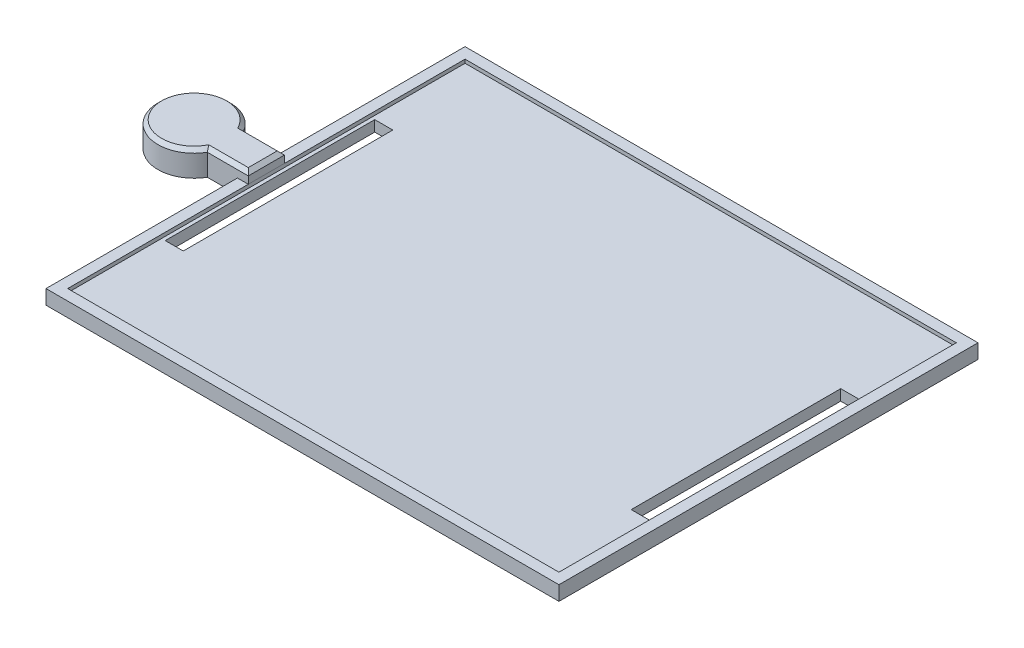
from build123d import *

# Parameters (mm, degrees)
SKETCH2_W                 = 142
SKETCH2_H                 = 116
BOSS_EXTRUDE2_DEPTH       = 4
SHELL1_T                  = -3
SKETCH4_W                 = 10
SKETCH4_H                 = 30
BOSS_EXTRUDE4_DEPTH       = 30
CUT_EXTRUDE1_DEPTH        = 31
CUT_EXTRUDE1_DEPTH_BACK   = 113
SKETCH6_W                 = 3
SKETCH6_H                 = 3.5
CUT_EXTRUDE2_DEPTH        = 31
CUT_EXTRUDE2_DEPTH_BACK   = 113
FILLET2_R                 = 2
SKETCH9_W                 = 22.5
SKETCH9_H                 = 12.1
CUT_EXTRUDE3_DEPTH        = 31
CUT_EXTRUDE3_DEPTH_BACK   = 10
SKETCH11_R                = 5.5
SKETCH11_R_2              = 4.25
BOSS_EXTRUDE6_DEPTH       = 17.5
M3X0_5_TAPPED_HOLE1_D     = 2.2
M3X0_5_TAPPED_HOLE1_DEPTH = 10
M3X0_5_TAPPED_HOLE1_TIP   = 0.660946681
SKETCH19_W                = 3
SKETCH19_H                = 10
BOSS_EXTRUDE7_DEPTH       = 3
BOSS_EXTRUDE7_DEPTH_BACK  = 4
CHAMFER1_SIZE             = 1
SKETCH27_W                = 14
SKETCH27_H                = 35
BOSS_EXTRUDE10_DEPTH      = 45
CUT_EXTRUDE4_DEPTH        = 45
SKETCH29_W                = 22.75
SKETCH29_H                = 12.15
CUT_EXTRUDE5_DEPTH        = 14
SKETCH37_R                = 4.25
CUT_EXTRUDE6_DEPTH        = 57.95
SKETCH38_W                = 5
SKETCH38_H                = 58
CUT_EXTRUDE7_DEPTH        = 8


with BuildPart() as part:
    # Sketch2 → Boss-Extrude2 (new body)
    with BuildSketch(Plane(origin=(0, 0, 0), x_dir=(1, 0, 0), z_dir=(0, 1, 0))):
        Rectangle(SKETCH2_W, SKETCH2_H)
    extrude(amount=BOSS_EXTRUDE2_DEPTH)

    # Shell1
    shell1_openings = [part.faces().sort_by_distance(p)[0] for p in [
        (0, 4, 0),
    ]]
    offset(amount=SHELL1_T, openings=shell1_openings, kind=Kind.INTERSECTION)

    # Sketch4 → Boss-Extrude4 (add)
    with BuildSketch(Plane.XZ):
        with Locations((-36, 0)):
            Rectangle(SKETCH4_W, SKETCH4_H)
        with Locations((19.05, 0)):
            Rectangle(SKETCH4_W, SKETCH4_H)
        with Locations((-10.95, 0)):
            Rectangle(SKETCH4_W, SKETCH4_H)
    extrude(amount=BOSS_EXTRUDE4_DEPTH)

    # Sketch5 → Cut-Extrude1 (cut, two sides)
    with BuildSketch(Plane.ZY.offset(41)) as cut_extrude1_sk:
        with BuildLine():
            ThreePointArc((-1.6e-08, -30), (-10.606601724, -25.606601712), (-15, -15))
            Line((-15, -15), (-15, -30))
            Line((-15, -30), (-1.6e-08, -30))
        make_face()
        with BuildLine():
            ThreePointArc((15, -15), (10.606601712, -25.606601724), (-1.6e-08, -30))
            Line((-1.6e-08, -30), (15, -30))
            Line((15, -30), (15, -15))
        make_face()
    extrude(amount=CUT_EXTRUDE1_DEPTH, mode=Mode.SUBTRACT)
    extrude(cut_extrude1_sk.sketch, amount=-CUT_EXTRUDE1_DEPTH_BACK, mode=Mode.SUBTRACT)

    # Sketch6 → Cut-Extrude2 (cut, two sides)
    with BuildSketch(Plane.ZY.offset(41)) as cut_extrude2_sk:
        with Locations((1.5, -1.75)):
            Rectangle(SKETCH6_W, SKETCH6_H)
    extrude(amount=CUT_EXTRUDE2_DEPTH, mode=Mode.SUBTRACT)
    extrude(cut_extrude2_sk.sketch, amount=-CUT_EXTRUDE2_DEPTH_BACK, mode=Mode.SUBTRACT)

    # Fillet2
    fillet2_edges = [part.edges().sort_by_distance(p)[0] for p in [
        (-31, 0, 9),
        (-41, 0, -7.5),
        (24.05, 0, 9),
        (14.05, 0, -7.5),
        (-5.95, 0, 9),
        (-15.95, 0, -7.5),
        (-31, 0, -7.5),
        (-41, 0, 9),
        (24.05, 0, -7.5),
        (14.05, 0, 9),
        (-5.95, 0, -7.5),
        (-15.95, 0, 9),
    ]]
    fillet(fillet2_edges, radius=FILLET2_R)

    # Sketch9 → Cut-Extrude3 (cut, two sides)
    with BuildSketch(Plane.ZY.offset(41)) as cut_extrude3_sk:
        with Locations((0, -15)):
            Rectangle(SKETCH9_W, SKETCH9_H)
    extrude(amount=CUT_EXTRUDE3_DEPTH, mode=Mode.SUBTRACT)
    extrude(cut_extrude3_sk.sketch, amount=-CUT_EXTRUDE3_DEPTH_BACK, mode=Mode.SUBTRACT)

    # Sketch11 → Boss-Extrude6 (add)
    with BuildSketch(Plane(origin=(-5.95, 0, 0), x_dir=(0, 0, -1), z_dir=(1, 0, 0))):
        with Locations((0, -20)):
            Circle(SKETCH11_R)
        with Locations((0, -20)):
            Circle(SKETCH11_R_2, mode=Mode.SUBTRACT)
    extrude(amount=BOSS_EXTRUDE6_DEPTH)

    # M3x0.5 Tapped Hole1
    with Locations(Plane.ZY.offset(41)):
        with Locations((13.85, -15)):
            Hole(M3X0_5_TAPPED_HOLE1_D / 2, depth=M3X0_5_TAPPED_HOLE1_DEPTH)
            with Locations((0, 0, -(M3X0_5_TAPPED_HOLE1_DEPTH + M3X0_5_TAPPED_HOLE1_TIP / 2))):  # 118° drill point
                Cone(0, M3X0_5_TAPPED_HOLE1_D / 2, M3X0_5_TAPPED_HOLE1_TIP, mode=Mode.SUBTRACT)

    # Sketch27 → Boss-Extrude10 (add)
    with BuildSketch(Plane.XZ):
        with Locations((-36, 2.5)):
            Rectangle(SKETCH27_W, SKETCH27_H)
    extrude(amount=BOSS_EXTRUDE10_DEPTH)

    # Sketch28 → Cut-Extrude4 (cut)
    with BuildSketch(Plane.ZY.offset(43)):
        with BuildLine():
            Line((15, 0), (15, -30))
            ThreePointArc((15, -30), (10.606601718, -40.606601718), (0, -45))
            Line((0, -45), (20, -45))
            Line((20, -45), (20, 0))
            Line((20, 0), (15, 0))
        make_face()
        with BuildLine():
            Line((-15, -45), (0, -45))
            ThreePointArc((0, -45), (-10.606601718, -40.606601718), (-15, -30))
            Line((-15, -30), (-15, -45))
        make_face()
    extrude(amount=-CUT_EXTRUDE4_DEPTH, mode=Mode.SUBTRACT)

    # Sketch29 → Cut-Extrude5 (cut)
    with BuildSketch(Plane.ZY.offset(43)):
        with Locations((0, -25)):
            Rectangle(SKETCH29_W, SKETCH29_H)
    extrude(amount=-CUT_EXTRUDE5_DEPTH, mode=Mode.SUBTRACT)

    # Sketch36 → M2 Clearance Hole1 (revolve, cut)
    with BuildSketch(Plane(origin=(-43, -25, 13.875), x_dir=(0, 0, 1), z_dir=(0, 1, 0))):
        Polygon((0, 0), (0, 14.721032743), (1.2, 14), (1.2, 0), align=None)
    revolve(axis=Axis((-49.35, -25, 13.875), (1, 0, 0)), mode=Mode.SUBTRACT)

    # Sketch37 → Cut-Extrude6 (cut, through all)
    with BuildSketch(Plane.ZY.offset(-14.05)):
        with Locations((0, -20)):
            Circle(SKETCH37_R)
    extrude(amount=-CUT_EXTRUDE6_DEPTH, mode=Mode.SUBTRACT)

    # Sketch38 → Cut-Extrude7 (cut, through all)
    with BuildSketch(Plane.XZ):
        with Locations((-64.5, 0)):
            Rectangle(SKETCH38_W, SKETCH38_H)
        with Locations((64.5, 0)):
            Rectangle(SKETCH38_W, SKETCH38_H)
    extrude(amount=-CUT_EXTRUDE7_DEPTH, mode=Mode.SUBTRACT)


with BuildPart() as body_2:
    # Sketch19 → Boss-Extrude7 (new body, two sides)
    with BuildSketch(Plane(origin=(0, 4, 0), x_dir=(1, 0, 0), z_dir=(0, 1, 0))) as boss_extrude7_sk:
        with BuildLine():
            ThreePointArc((-78, 0), (-78.340741737, 2.588190451), (-79.339745962, 5))
            Line((-79.339745962, 5), (-88, 5))
            Line((-88, 5), (-88, -5))
            Line((-88, -5), (-79.339745962, -5))
            ThreePointArc((-79.339745962, -5), (-78.340741737, -2.588190451), (-78, 0))
        make_face()
        with BuildLine():
            Line((-88, 5), (-79.339745962, 5))
            ThreePointArc((-79.339745962, 5), (-98, 0), (-79.339745962, -5))
            Line((-79.339745962, -5), (-88, -5))
            Line((-88, -5), (-88, 5))
        make_face()
        with BuildLine():
            Line((-71, -5), (-71, 5))
            Line((-71, 5), (-79.339745962, 5))
            ThreePointArc((-79.339745962, 5), (-78.340741737, 2.588190451), (-78, 0))
            ThreePointArc((-78, 0), (-78.340741737, -2.588190451), (-79.339745962, -5))
            Line((-79.339745962, -5), (-71, -5))
        make_face()
        with Locations((-69.5, 0)):
            Rectangle(SKETCH19_W, SKETCH19_H)
    extrude(amount=BOSS_EXTRUDE7_DEPTH)
    extrude(boss_extrude7_sk.sketch, amount=-BOSS_EXTRUDE7_DEPTH_BACK)

    # Chamfer1
    chamfer1_edges = [body_2.edges().sort_by_distance(p)[0] for p in [
        (-73.669872981, 7, 5),
        (-98, 7, 0),
        (-68, 7, 0),
        (-73.669872981, 7, -5),
    ]]
    chamfer(chamfer1_edges, length=CHAMFER1_SIZE)


solid = Compound([part.part, body_2.part])
